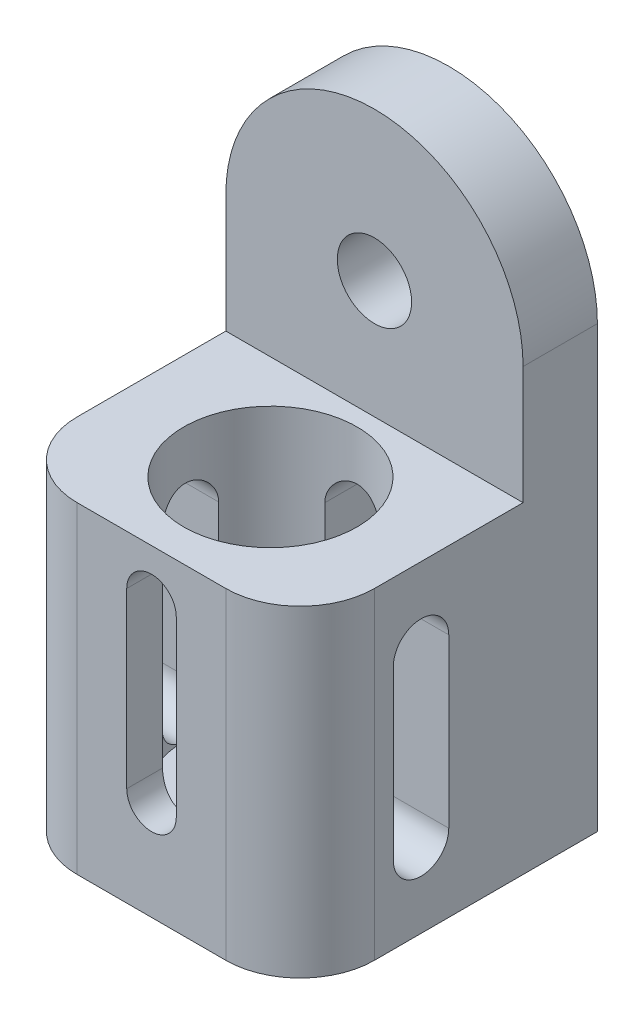
from build123d import *

# Parameters (mm, degrees)
BOSS_EXTRUDE1_DEPTH         = 150.876
CUT_EXTRUDE1_DEPTH          = 77.2
SKETCH3_W                   = 57.15
SKETCH3_H                   = 68.326
CUT_EXTRUDE2_DEPTH          = 77.2000001
F_3_4_0_75_DIAMETER_HOLE1_D = 19.05
SKETCH6_R                   = 22.225
CUT_EXTRUDE3_DEPTH          = 69.85
CUT_EXTRUDE4_REACH          = 78.2
CUT_EXTRUDE5_DEPTH          = 17.222112
CUT_EXTRUDE6_REACH          = 78.2


with BuildPart() as part:
    # Sketch1 → Boss-Extrude1 (new body)
    with BuildSketch(Plane(origin=(0, 0, 0), x_dir=(1, 0, 0), z_dir=(0, 1, 0))):
        with BuildLine():
            Line((-19.05, -38.1), (19.05, -38.1))
            ThreePointArc((19.05, -38.1), (32.520384182, -32.520384182), (38.1, -19.05))
            Line((38.1, -19.05), (38.1, 38.1))
            Line((38.1, 38.1), (-38.1, 38.1))
            Line((-38.1, 38.1), (-38.1, -19.05))
            ThreePointArc((-38.1, -19.05), (-32.520384182, -32.520384182), (-19.05, -38.1))
        make_face()
    extrude(amount=BOSS_EXTRUDE1_DEPTH)

    # Sketch2 → Cut-Extrude1 (cut, through all)
    with BuildSketch(Plane.XY.offset(38.1)):
        with BuildLine():
            Line((38.1, 150.876), (19.05, 150.876))
            Line((19.05, 150.876), (19.05, 145.771567884))
            ThreePointArc((19.05, 145.771567884), (32.995567884, 131.826), (38.1, 112.776))
            Line((38.1, 112.776), (38.1, 150.876))
        make_face()
        with BuildLine():
            Line((19.05, 150.876), (5.6e-08, 150.876))
            ThreePointArc((5.6e-08, 150.876), (9.861005645, 149.577773974), (19.05, 145.771567884))
            Line((19.05, 145.771567884), (19.05, 150.876))
        make_face()
        with BuildLine():
            Line((-19.05, 150.876), (-19.05, 145.771567884))
            ThreePointArc((-19.05, 145.771567884), (-9.861005591, 149.577773989), (5.6e-08, 150.876))
            Line((5.6e-08, 150.876), (-19.05, 150.876))
        make_face()
        with BuildLine():
            Line((-38.1, 150.876), (-38.1, 112.776))
            ThreePointArc((-38.1, 112.776), (-32.995567884, 131.826), (-19.05, 145.771567884))
            Line((-19.05, 145.771567884), (-19.05, 150.876))
            Line((-19.05, 150.876), (-38.1, 150.876))
        make_face()
    extrude(amount=-CUT_EXTRUDE1_DEPTH, mode=Mode.SUBTRACT)

    # Sketch3 → Cut-Extrude2 (cut, through all)
    with BuildSketch(Plane(origin=(38.1, 0, 0), x_dir=(0, 0, -1), z_dir=(1, 0, 0))):
        with Locations((-9.525, 116.713)):
            Rectangle(SKETCH3_W, SKETCH3_H)
    extrude(amount=-CUT_EXTRUDE2_DEPTH, mode=Mode.SUBTRACT)

    # 3/4 (0.75) Diameter Hole1 (through all)
    with Locations(Plane.XY.offset(-19.05)):
        with Locations((0, 112.776)):
            Hole(F_3_4_0_75_DIAMETER_HOLE1_D / 2)

    # Sketch6 → Cut-Extrude3 (cut)
    with BuildSketch(Plane(origin=(0, 82.55, 0), x_dir=(1, 0, 0), z_dir=(0, 1, 0))):
        with Locations((0, -7.62)):
            Circle(SKETCH6_R)
    extrude(amount=-CUT_EXTRUDE3_DEPTH, mode=Mode.SUBTRACT)

    # Sketch7 → Cut-Extrude4 (cut, up to next)
    with BuildSketch(Plane.XY.offset(38.1), mode=Mode.PRIVATE) as cut_extrude4_sk1:
        with BuildLine():
            Line((-6.35, 25.4), (-6.35, 69.85))
            ThreePointArc((-6.35, 69.85), (0, 76.2), (6.35, 69.85))
            Line((6.35, 69.85), (6.35, 25.4))
            ThreePointArc((6.35, 25.4), (0, 19.05), (-6.35, 25.4))
        make_face()
    cut_extrude4_tool1 = extrude(cut_extrude4_sk1.sketch, amount=-CUT_EXTRUDE4_REACH, mode=Mode.PRIVATE) & part.part
    add(cut_extrude4_tool1.solids().sort_by_distance((0, 47.625, 38.1))[0], mode=Mode.SUBTRACT)

    # Sketch8 → Cut-Extrude5 (cut)
    with BuildSketch(Plane(origin=(38.1, 0, 0), x_dir=(0, 0, -1), z_dir=(1, 0, 0))):
        with BuildLine():
            Line((0, 62.738), (0, 19.812))
            ThreePointArc((0, 19.812), (-7.112, 12.7), (-14.224, 19.812))
            Line((-14.224, 19.812), (-14.224, 62.738))
            ThreePointArc((-14.224, 62.738), (-7.112, 69.85), (0, 62.738))
        make_face()
    cut_extrude5 = extrude(amount=-CUT_EXTRUDE5_DEPTH, mode=Mode.SUBTRACT)

    # Mirror1: Cut-Extrude5 across plane
    add(cut_extrude5.mirror(Plane(origin=(0, 0, 0), x_dir=(0, 0, 1), z_dir=(1, 0, 0))), mode=Mode.SUBTRACT)

    # Sketch9 → Cut-Extrude6 (cut, up to next)
    with BuildSketch(Plane(origin=(0, 0, -38.1), x_dir=(-1, 0, 0), z_dir=(0, 0, -1)), mode=Mode.PRIVATE) as cut_extrude6_sk1:
        with BuildLine():
            Line((-7.112, 19.812), (-7.112, 62.738))
            ThreePointArc((-7.112, 62.738), (0, 69.85), (7.112, 62.738))
            Line((7.112, 62.738), (7.112, 19.812))
            ThreePointArc((7.112, 19.812), (0, 12.7), (-7.112, 19.812))
        make_face()
    cut_extrude6_tool1 = extrude(cut_extrude6_sk1.sketch, amount=-CUT_EXTRUDE6_REACH, mode=Mode.PRIVATE) & part.part
    add(cut_extrude6_tool1.solids().sort_by_distance((0, 41.275, -38.1))[0], mode=Mode.SUBTRACT)


solid = part.part
